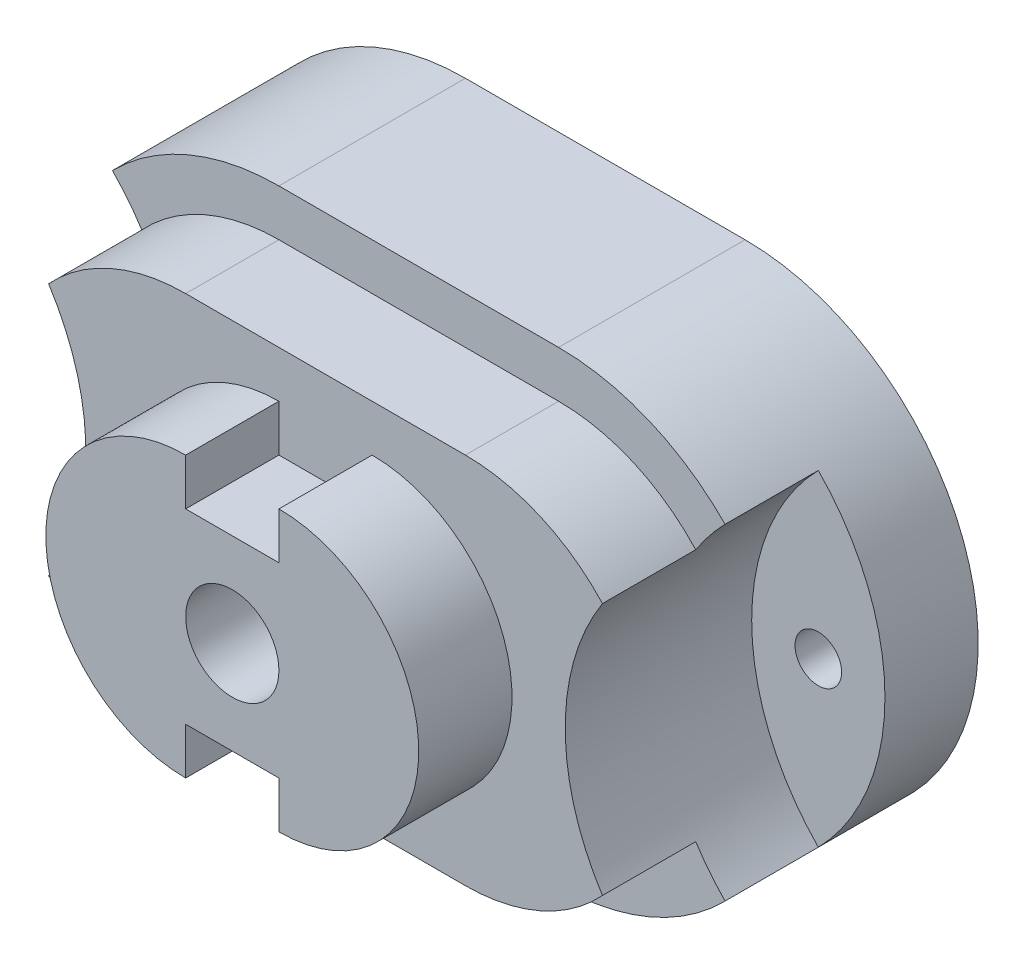
from build123d import *

# Parameters (mm, degrees)
BOSS_EXTRUDE1_DEPTH            = 20
CUT_EXTRUDE10_DEPTH            = 10
CUT_EXTRUDE11_DEPTH            = 10
BOSS_EXTRUDE4_DEPTH            = 10
CUT_EXTRUDE16_DEPTH            = 20
BOSS_EXTRUDE6_DEPTH            = 10
SKETCH15_R                     = 2.5
CUT_EXTRUDE17_DEPTH            = 33
F_1_2_1_2_DIAMETER_HOLE2_D     = 10
F_1_2_1_2_DIAMETER_HOLE2_DEPTH = 20
F_1_2_1_2_DIAMETER_HOLE2_TIP   = 2.714778498


with BuildPart() as part:
    # Sketch1 → Boss-Extrude1 (new body)
    with BuildSketch(Plane.XY):
        with BuildLine():
            Line((-30, 50), (0, 50))
            ThreePointArc((0, 50), (25, 25), (0, 0))
            Line((0, 0), (-30, 0))
            ThreePointArc((-30, 0), (-55, 25), (-30, 50))
        make_face()
    extrude(amount=BOSS_EXTRUDE1_DEPTH)

    # Sketch2 → Cut-Extrude10 (cut)
    with BuildSketch(Plane.XY.offset(20)):
        with BuildLine():
            ThreePointArc((-47.853571071, 42.5), (-55, 25), (-47.853571071, 7.5))
            Line((-47.853571071, 7.5), (-47.853571071, 42.5))
        make_face()
    extrude(amount=-CUT_EXTRUDE10_DEPTH, mode=Mode.SUBTRACT)

    # Sketch9 → Cut-Extrude11 (cut)
    with BuildSketch(Plane.XY.offset(20)):
        with BuildLine():
            Line((17.853571071, 42.5), (17.853571071, 7.5))
            ThreePointArc((17.853571071, 7.5), (25, 25), (17.853571071, 42.5))
        make_face()
    extrude(amount=-CUT_EXTRUDE11_DEPTH, mode=Mode.SUBTRACT)

    # Sketch10 → Boss-Extrude4 (add)
    with BuildSketch(Plane.XY.offset(20)):
        with BuildLine():
            Line((-30, 45), (0, 45))
            ThreePointArc((0, 45), (20, 25), (0, 5))
            Line((0, 5), (-30, 5))
            ThreePointArc((-30, 5), (-50, 25), (-30, 45))
        make_face()
    extrude(amount=BOSS_EXTRUDE4_DEPTH)

    # Sketch11 → Cut-Extrude16 (cut)
    with BuildSketch(Plane.XY.offset(30)):
        with BuildLine():
            ThreePointArc((-47.853571071, 42.5), (-40.707142143, 25), (-47.853571071, 7.5))
            ThreePointArc((-47.853571071, 7.5), (-55, 25), (-47.853571071, 42.5))
        make_face()
        with BuildLine():
            ThreePointArc((17.853571071, 42.5), (10.707142143, 25), (17.853571071, 7.5))
            ThreePointArc((17.853571071, 7.5), (25, 25), (17.853571071, 42.5))
        make_face()
    extrude(amount=-CUT_EXTRUDE16_DEPTH, mode=Mode.SUBTRACT)

    # Sketch14 → Boss-Extrude6 (add)
    with BuildSketch(Plane.XY.offset(30)):
        with BuildLine():
            Line((-20, 40), (-20, 35))
            Line((-20, 35), (-10, 35))
            Line((-10, 35), (-10, 40))
            ThreePointArc((-10, 40), (5, 25), (-10, 10))
            Line((-10, 10), (-10, 15))
            Line((-10, 15), (-20, 15))
            Line((-20, 15), (-20, 10))
            ThreePointArc((-20, 10), (-35, 25), (-20, 40))
        make_face()
    extrude(amount=BOSS_EXTRUDE6_DEPTH)

    # Sketch15 → Cut-Extrude17 (cut)
    with BuildSketch(Plane.XY.offset(10)):
        with Locations((17.853571071, 25)):
            Circle(SKETCH15_R)
        with Locations((-47.853571071, 25)):
            Circle(SKETCH15_R)
    extrude(amount=-CUT_EXTRUDE17_DEPTH, mode=Mode.SUBTRACT)

    # Ø1.2 (1.2) Diameter Hole2
    with Locations(Plane(origin=(-15, 25, 40), x_dir=(1, 0, 0), z_dir=(0, 0, 1))):
        with Locations((0, 0)):
            Hole(F_1_2_1_2_DIAMETER_HOLE2_D / 2, depth=F_1_2_1_2_DIAMETER_HOLE2_DEPTH)
            with Locations((0, 0, -(F_1_2_1_2_DIAMETER_HOLE2_DEPTH + F_1_2_1_2_DIAMETER_HOLE2_TIP / 2))):  # 123° drill point
                Cone(0, F_1_2_1_2_DIAMETER_HOLE2_D / 2, F_1_2_1_2_DIAMETER_HOLE2_TIP, mode=Mode.SUBTRACT)


solid = part.part
